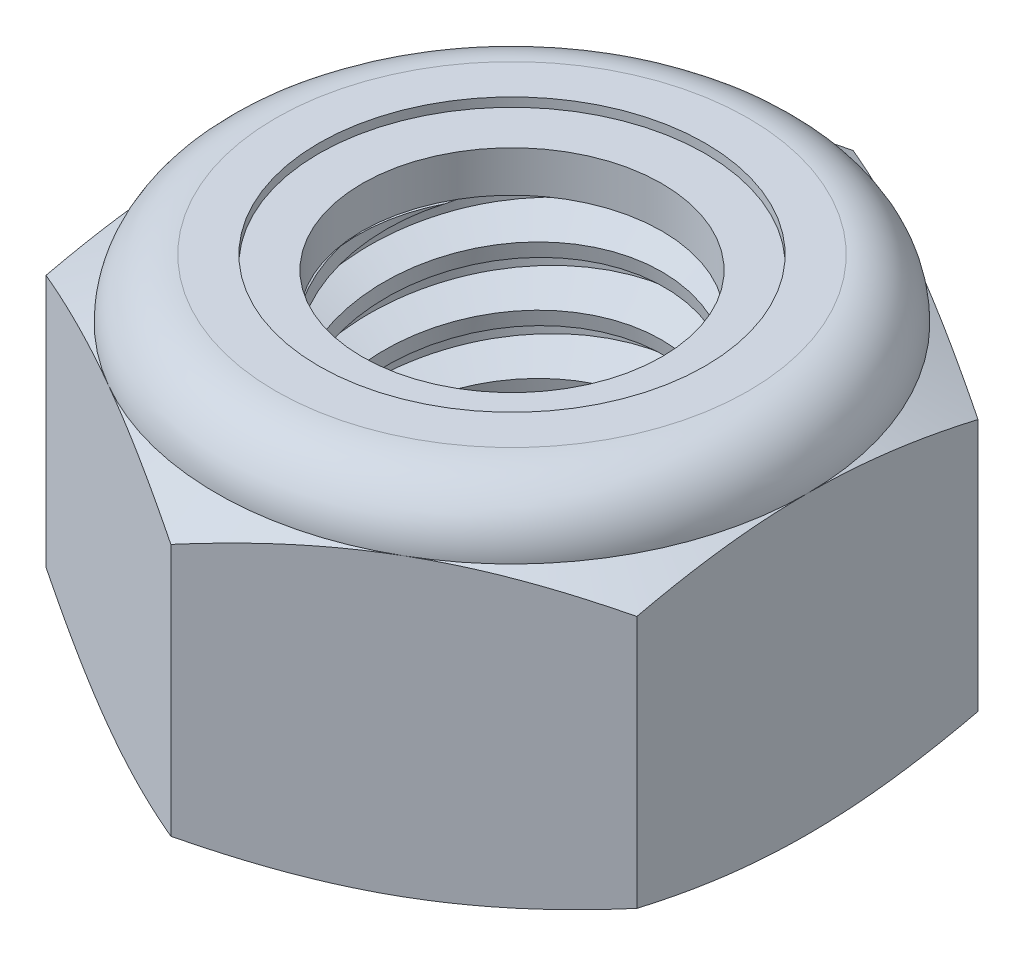
from build123d import *

# Parameters (mm, degrees)
EXTRUDE1_DEPTH      = 6
SKETCH2_W           = 3
SKETCH2_H           = 6
LPATTERN1_COUNT     = 6
LPATTERN1_PITCH     = 1
LPATTERN1_COL_COUNT = 2
LPATTERN1_COL_PITCH = 1


with BuildPart() as part:
    # Sketch1 → Extrude1 (new body)
    with BuildSketch(Plane(origin=(0, 0, 0), x_dir=(1, 0, 0), z_dir=(0, 1, 0))):
        Polygon((0, 5.773502692), (-5, 2.886751346), (-5, -2.886751346), (0, -5.773502692), (5, -2.886751346), (5, 2.886751346), align=None)
    extrude(amount=EXTRUDE1_DEPTH)

    # Sketch4 → Cut-Revolve2 (revolve, cut)
    with BuildSketch(Plane(origin=(0, 0, 0), x_dir=(0, 0, -1), z_dir=(1, 0, 0))):
        Polygon((0, 6), (3, 6), (2.538023184, 5.784576673), (2.538023184, 0.215423327), (3, 0), (0, 0), align=None)
    revolve(axis=Axis((0, 6, 0), (0, 1, 0)), mode=Mode.SUBTRACT)


with BuildPart() as body_2:
    # Sketch2 → Revolve1 (revolve)
    with BuildSketch(Plane(origin=(0, 0, 0), x_dir=(0, 0, -1), z_dir=(1, 0, 0))):
        with Locations((1.5, 3)):
            Rectangle(SKETCH2_W, SKETCH2_H)
    revolve(axis=Axis((0, -3, 0), (0, 1, 0)))

    # Sketch3 → Cut-Revolve1 (revolve, cut)
    with BuildSketch(Plane(origin=(0, 0, 0), x_dir=(0, 0, -1), z_dir=(1, 0, 0))):
        Polygon((3.020549873, 5.87670076), (3.164398987, 5.013606076), (2.579122931, 5.232870615), (2.538023184, 5.479469096), align=None)
    cut_revolve1 = revolve(axis=Axis((0, 6, 0.178376498), (0, -0.986393924, -0.164398987)), mode=Mode.SUBTRACT)

    # LPattern1: Cut-Revolve1 ×6
    with Locations(*[(0, -i * LPATTERN1_PITCH, 0) for i in range(1, LPATTERN1_COUNT)]):
        add(cut_revolve1, mode=Mode.SUBTRACT)

    # LPattern1 col: Cut-Revolve1 ×2
    with Locations(*[(0, i * LPATTERN1_COL_PITCH, 0) for i in range(1, LPATTERN1_COL_COUNT)]):
        add(cut_revolve1, mode=Mode.SUBTRACT)


with BuildPart() as part_1:
    add(part.part)

    # Combine1: cut body 2
    add(body_2.part, mode=Mode.SUBTRACT)

    # Sketch5 → Cut-Revolve3 (revolve, cut)
    with BuildSketch(Plane(origin=(0, 0, 0), x_dir=(0, 0, -1), z_dir=(1, 0, 0))):
        with BuildLine():
            Line((0, 0), (5, 0))
            Line((5, 0), (5.773502692, 0.360690229))
            Line((5.773502692, 0.360690229), (5.773502692, 4.639309771))
            Line((5.773502692, 4.639309771), (5, 5))
            ThreePointArc((5, 5), (4.707106781, 5.707106781), (4, 6))
            Line((4, 6), (4, 7.27))
            Line((4, 7.27), (7.043502692, 7.27))
            Line((7.043502692, 7.27), (7.043502692, -1.27))
            Line((7.043502692, -1.27), (0, -1.27))
            Line((0, -1.27), (0, 0))
        make_face()
    revolve(axis=Axis((0, 0, 0), (0, 1, 0)), mode=Mode.SUBTRACT)

    # Sketch6 → Cut-Revolve4 (revolve, cut)
    with BuildSketch(Plane(origin=(0, 0, 0), x_dir=(0, 0, -1), z_dir=(1, 0, 0))):
        with BuildLine():
            Line((0, 5), (4.8476, 5))
            ThreePointArc((4.8476, 5), (4.599343708, 5.599343708), (4, 5.8476))
            Line((4, 5.8476), (3.269011592, 5.8476))
            Line((3.269011592, 5.8476), (3.269011592, 7.27))
            Line((3.269011592, 7.27), (0, 7.27))
            Line((0, 7.27), (0, 5))
        make_face()
    revolve(axis=Axis((0, 7.27, 0), (0, 1, 0)), mode=Mode.SUBTRACT)


with BuildPart() as body_2_2:
    # Sketch7 → Revolve2 (revolve)
    with BuildSketch(Plane(origin=(0, 0, 0), x_dir=(0, 0, -1), z_dir=(1, 0, 0))):
        with BuildLine():
            Line((2.538023184, 5.0762), (4.767627201, 5.0762))
            ThreePointArc((4.767627201, 5.0762), (4.51782105, 5.57176859), (4, 5.7714))
            Line((4, 5.7714), (2.538023184, 5.7714))
            Line((2.538023184, 5.7714), (2.538023184, 5.0762))
        make_face()
    revolve(axis=Axis((0, 5.0762, 0), (0, 1, 0)))


solid = Compound([part_1.part, body_2_2.part])
